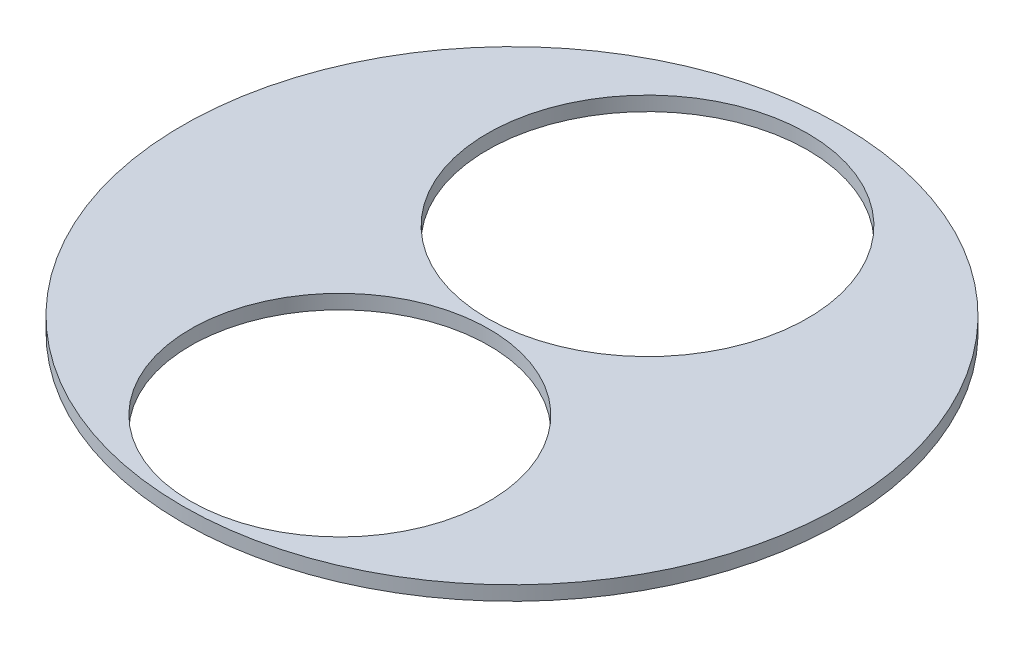
from build123d import *

# Parameters (mm, degrees)
SKETCH1_R           = 1149.985
SKETCH1_R_2         = 558.8
SKETCH1_R_3         = 520.7
BOSS_EXTRUDE1_DEPTH = 50


with BuildPart() as part:
    # Sketch1 → Boss-Extrude1 (new body)
    with BuildSketch(Plane(origin=(0, 0, 0), x_dir=(1, 0, 0), z_dir=(0, 1, 0))):
        Circle(SKETCH1_R)
        with Locations((-35.215829478, 508.071242417)):
            Circle(SKETCH1_R_2, mode=Mode.SUBTRACT)
        with Locations((0, -600.758907487)):
            Circle(SKETCH1_R_3, mode=Mode.SUBTRACT)
    extrude(amount=BOSS_EXTRUDE1_DEPTH)


solid = part.part
